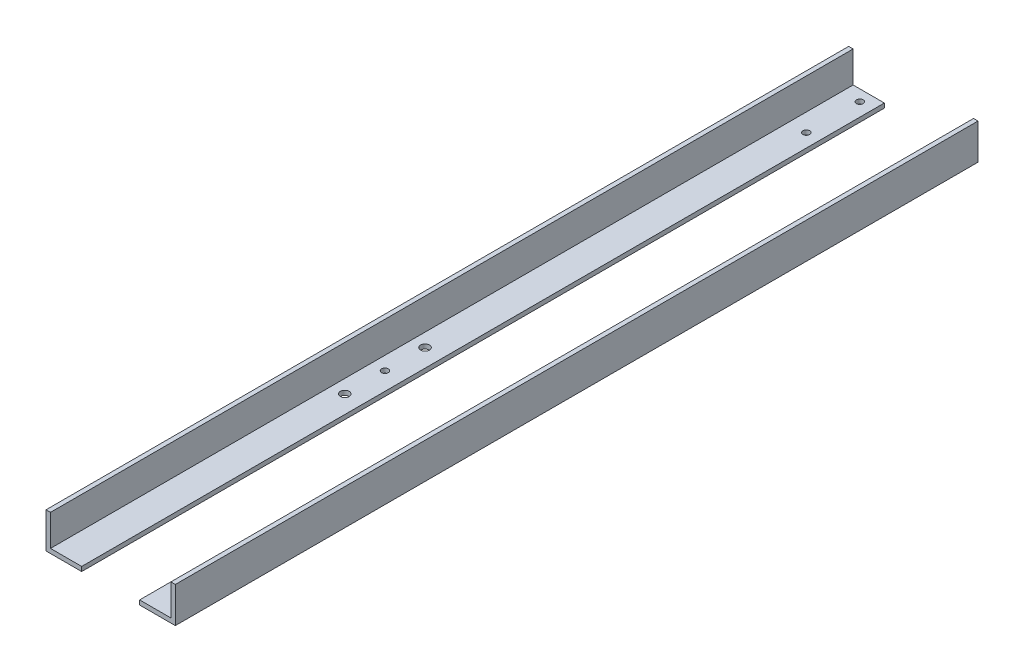
from build123d import *

# Parameters (mm, degrees)
SKETCH1_W            = 184.15
SKETCH1_H            = 1143
BOSS_EXTRUDE1_DEPTH  = 50.8
CUT_EXTRUDE1_DEPTH   = 1144
SKETCH3_R            = 4.7625
SKETCH3_R_2          = 6.35
BOLT_HOLE_CUTS_DEPTH = 7.35


with BuildPart() as part:
    # Sketch1 → Boss-Extrude1 (new body)
    with BuildSketch(Plane(origin=(0, 0, 0), x_dir=(1, 0, 0), z_dir=(0, 1, 0))):
        Rectangle(SKETCH1_W, SKETCH1_H)
    extrude(amount=BOSS_EXTRUDE1_DEPTH)

    # Sketch2 → Cut-Extrude1 (cut, through all)
    with BuildSketch(Plane.XY.offset(571.5)):
        Polygon((-85.725, 50.8), (85.725, 50.8), (85.725, 6.35), (41.275, 6.35), (41.275, 0), (-41.275, 0), (-41.275, 6.35), (-85.725, 6.35), align=None)
    extrude(amount=-CUT_EXTRUDE1_DEPTH, mode=Mode.SUBTRACT)

    # Sketch3 → Bolt Hole Cuts (cut, through all)
    with BuildSketch(Plane(origin=(0, 6.35, 0), x_dir=(1, 0, 0), z_dir=(0, 1, 0))):
        with Locations((-60.325, 555.625)):
            Circle(SKETCH3_R)
        with Locations((-60.325, 479.425)):
            Circle(SKETCH3_R)
        with Locations((-66.675, -114.3)):
            Circle(SKETCH3_R)
        with Locations((60.325, 555.625)):
            Circle(SKETCH3_R)
        with Locations((60.325, 479.425)):
            Circle(SKETCH3_R)
        with Locations((60.325, -114.3)):
            Circle(SKETCH3_R)
        with Locations((-66.675, -57.15)):
            Circle(SKETCH3_R_2)
        with Locations((-66.675, -171.45)):
            Circle(SKETCH3_R_2)
        with Locations((60.325, -57.15)):
            Circle(SKETCH3_R_2)
        with Locations((60.325, -171.45)):
            Circle(SKETCH3_R_2)
    extrude(amount=-BOLT_HOLE_CUTS_DEPTH, mode=Mode.SUBTRACT)


solid = part.part
